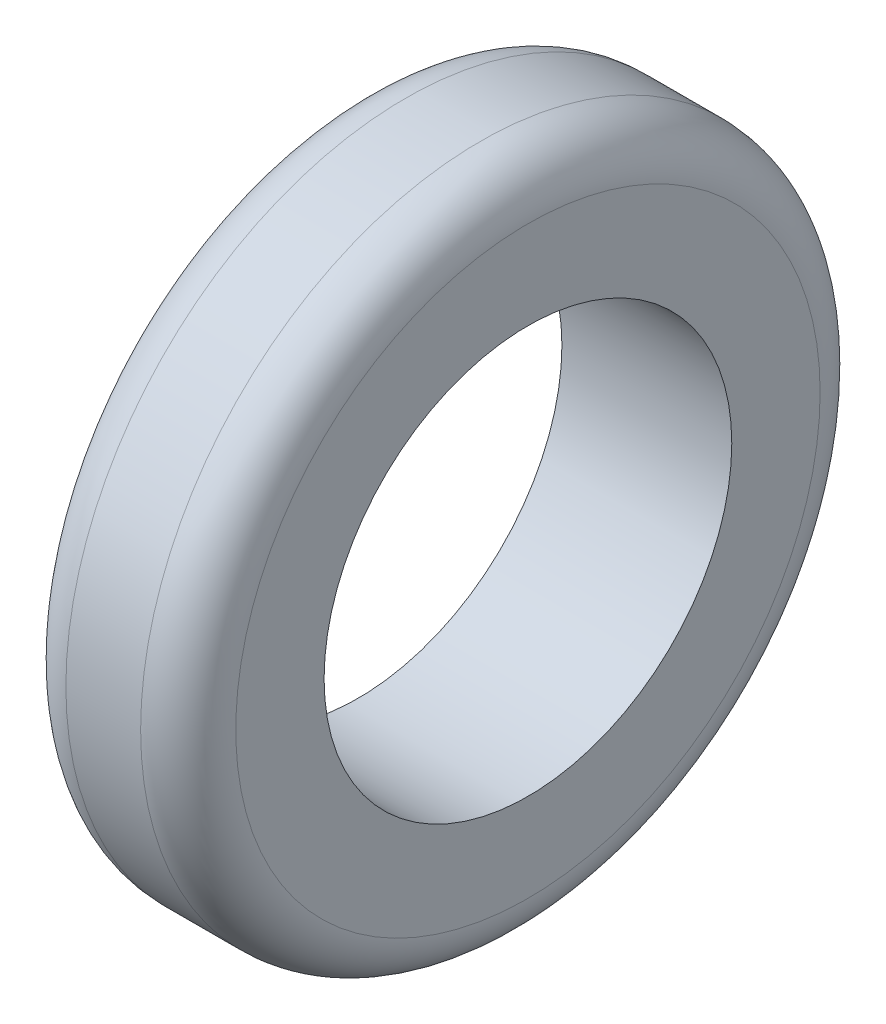
from build123d import *

# Parameters (mm, degrees)
SKETCH1_R           = 50
SKETCH1_R_2         = 30
BOSS_EXTRUDE1_DEPTH = 25
FILLET1_R           = 7


with BuildPart() as part:
    # Sketch1 → Boss-Extrude1 (new body)
    with BuildSketch(Plane(origin=(0, 0, 0), x_dir=(0, 0, -1), z_dir=(1, 0, 0))):
        Circle(SKETCH1_R)
        Circle(SKETCH1_R_2, mode=Mode.SUBTRACT)
    extrude(amount=BOSS_EXTRUDE1_DEPTH)

    # Fillet1
    fillet1_edges = [part.edges().sort_by_distance(p)[0] for p in [
        (0, 0, 50),
        (25, 0, 50),
    ]]
    fillet(fillet1_edges, radius=FILLET1_R)


solid = part.part
